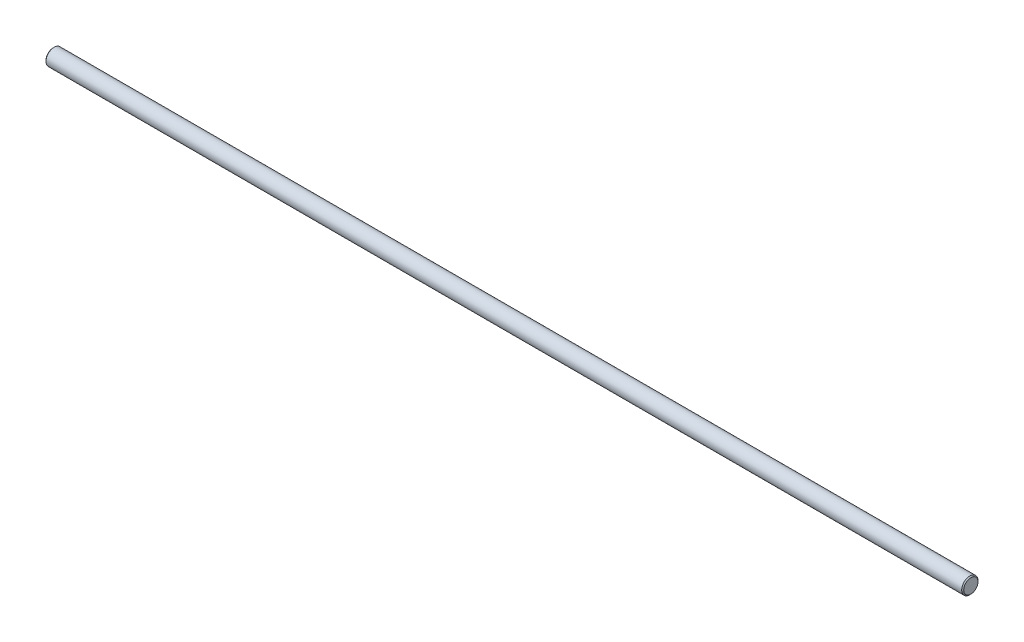
from build123d import *

# Parameters (mm, degrees)
SKETCH1_R           = 4
BOSS_EXTRUDE1_DEPTH = 450
CHAMFER1_SIZE       = 0.5


with BuildPart() as part:
    # Sketch1 → Boss-Extrude1 (new body)
    with BuildSketch(Plane(origin=(0, 0, 0), x_dir=(0, 0, -1), z_dir=(1, 0, 0))):
        Circle(SKETCH1_R)
    extrude(amount=BOSS_EXTRUDE1_DEPTH)

    # Chamfer1
    chamfer1_edges = [part.edges().sort_by_distance(p)[0] for p in [
        (0, 0, 4),
        (450, 0, 4),
    ]]
    chamfer(chamfer1_edges, length=CHAMFER1_SIZE)


solid = part.part
